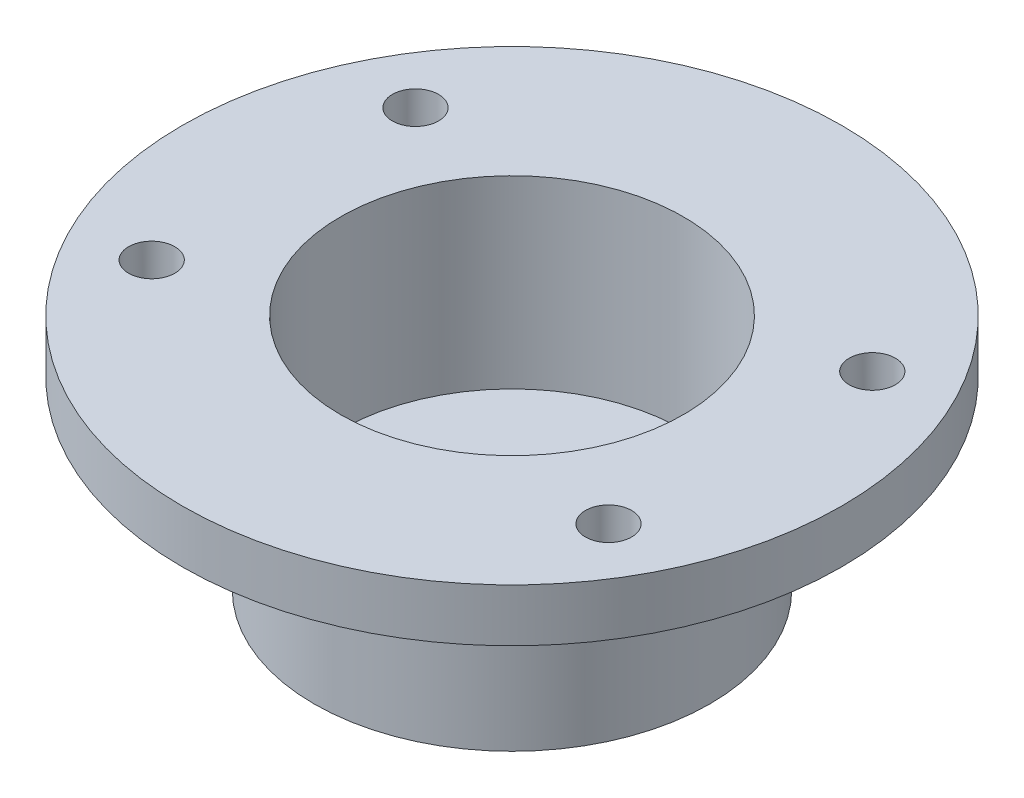
from build123d import *

# Parameters (mm, degrees)
SKETCH1_R           = 15
SKETCH1_R_2         = 3
BOSS_EXTRUDE1_DEPTH = 4
SKETCH2_R           = 15
SKETCH2_R_2         = 13
EXTRUDE_THIN1_DEPTH = 10
SKETCH3_R           = 25
SKETCH3_R_2         = 13
BOSS_EXTRUDE2_DEPTH = 4
CUT_EXTRUDE1_REACH  = 20
SKETCH4_R           = 1.75


with BuildPart() as part:
    # Sketch1 → Boss-Extrude1 (new body)
    with BuildSketch(Plane(origin=(0, 0, 0), x_dir=(1, 0, 0), z_dir=(0, 1, 0))):
        Circle(SKETCH1_R)
        Circle(SKETCH1_R_2, mode=Mode.SUBTRACT)
    extrude(amount=BOSS_EXTRUDE1_DEPTH)

    # Sketch2 → Extrude-Thin1 (add)
    with BuildSketch(Plane(origin=(0, 4, 0), x_dir=(1, 0, 0), z_dir=(0, 1, 0))):
        Circle(SKETCH2_R)
        Circle(SKETCH2_R_2, mode=Mode.SUBTRACT)
    extrude(amount=EXTRUDE_THIN1_DEPTH)

    # Sketch3 → Boss-Extrude2 (add)
    with BuildSketch(Plane(origin=(0, 14, 0), x_dir=(1, 0, 0), z_dir=(0, 1, 0))):
        Circle(SKETCH3_R)
        Circle(SKETCH3_R_2, mode=Mode.SUBTRACT)
    extrude(amount=BOSS_EXTRUDE2_DEPTH)

    # Sketch4 → Cut-Extrude1 (cut, up to next)
    with BuildSketch(Plane(origin=(0, 18, 0), x_dir=(1, 0, 0), z_dir=(0, 1, 0)), mode=Mode.PRIVATE) as cut_extrude1_sk1:
        with Locations((-17.320508076, 10)):
            Circle(SKETCH4_R)
    cut_extrude1_tool1 = extrude(cut_extrude1_sk1.sketch, amount=-CUT_EXTRUDE1_REACH, mode=Mode.PRIVATE) & part.part
    add(cut_extrude1_tool1.solids().sort_by_distance((-17.320508, 18, -10))[0], mode=Mode.SUBTRACT)
    # Sketch4 → Cut-Extrude1 (cut, up to next)
    with BuildSketch(Plane(origin=(0, 18, 0), x_dir=(1, 0, 0), z_dir=(0, 1, 0)), mode=Mode.PRIVATE) as cut_extrude1_sk2:
        with Locations((17.320508076, 10)):
            Circle(SKETCH4_R)
    cut_extrude1_tool2 = extrude(cut_extrude1_sk2.sketch, amount=-CUT_EXTRUDE1_REACH, mode=Mode.PRIVATE) & part.part
    add(cut_extrude1_tool2.solids().sort_by_distance((17.320508, 18, -10))[0], mode=Mode.SUBTRACT)
    # Sketch4 → Cut-Extrude1 (cut, up to next)
    with BuildSketch(Plane(origin=(0, 18, 0), x_dir=(1, 0, 0), z_dir=(0, 1, 0)), mode=Mode.PRIVATE) as cut_extrude1_sk3:
        with Locations((17.320508076, -10)):
            Circle(SKETCH4_R)
    cut_extrude1_tool3 = extrude(cut_extrude1_sk3.sketch, amount=-CUT_EXTRUDE1_REACH, mode=Mode.PRIVATE) & part.part
    add(cut_extrude1_tool3.solids().sort_by_distance((17.320508, 18, 10))[0], mode=Mode.SUBTRACT)
    # Sketch4 → Cut-Extrude1 (cut, up to next)
    with BuildSketch(Plane(origin=(0, 18, 0), x_dir=(1, 0, 0), z_dir=(0, 1, 0)), mode=Mode.PRIVATE) as cut_extrude1_sk4:
        with Locations((-17.320508076, -10)):
            Circle(SKETCH4_R)
    cut_extrude1_tool4 = extrude(cut_extrude1_sk4.sketch, amount=-CUT_EXTRUDE1_REACH, mode=Mode.PRIVATE) & part.part
    add(cut_extrude1_tool4.solids().sort_by_distance((-17.320508, 18, 10))[0], mode=Mode.SUBTRACT)


solid = part.part
